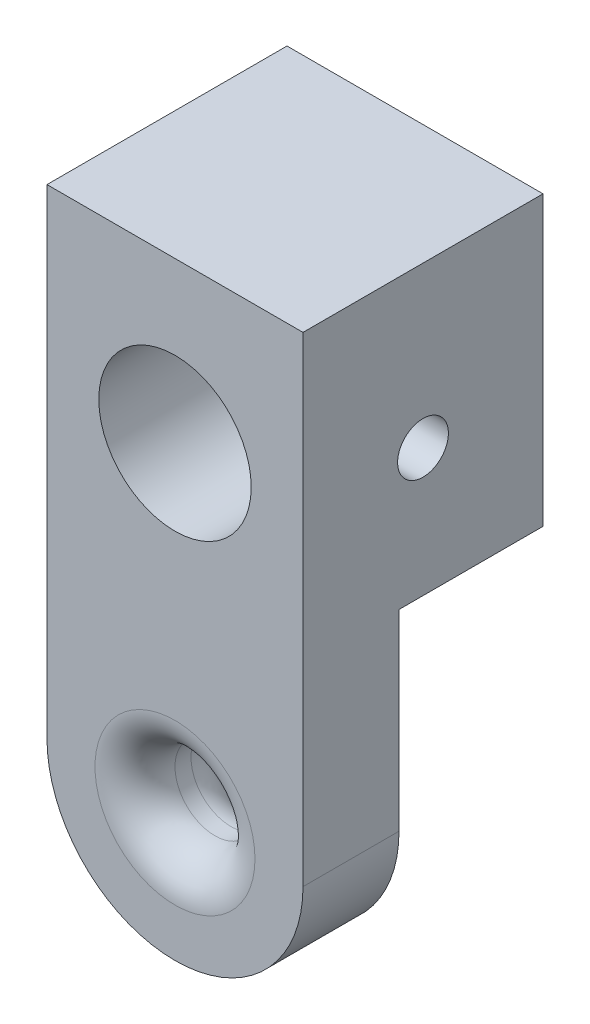
from build123d import *

# Parameters (mm, degrees)
SKETCH1_R                  = 2.5
BOSS_EXTRUDE1_DEPTH        = 15
SKETCH6_W                  = 16
SKETCH6_H                  = 20
CUT_EXTRUDE1_DEPTH         = 9
FILLET1_R                  = 2.5
F_3_8_0_3750_DOWEL_HOLE1_D = 9.525
F_1_8_0_1250_DOWEL_HOLE1_D = 3.175


with BuildPart() as part:
    # Sketch1 → Boss-Extrude1 (new body)
    with BuildSketch(Plane.XY):
        with BuildLine():
            Line((-8, 12), (-8, 0))
            ThreePointArc((-8, 0), (0, -8), (8, 0))
            Line((8, 0), (8, 12))
            Line((8, 12), (8, 30))
            Line((8, 30), (-8, 30))
            Line((-8, 30), (-8, 12))
        make_face()
        Circle(SKETCH1_R, mode=Mode.SUBTRACT)
    extrude(amount=BOSS_EXTRUDE1_DEPTH)

    # Sketch6 → Cut-Extrude1 (cut)
    with BuildSketch(Plane.XY):
        with Locations((0, 2)):
            Rectangle(SKETCH6_W, SKETCH6_H)
    extrude(amount=CUT_EXTRUDE1_DEPTH, mode=Mode.SUBTRACT)

    # Fillet1
    fillet1_edges = [part.edges().sort_by_distance(p)[0] for p in [
        (-2.5, 0, 15),
        (-2.5, 0, 9),
    ]]
    fillet(fillet1_edges, radius=FILLET1_R)

    # 3/8 (0.3750) Dowel Hole1 (through all)
    with Locations(Plane.XY.offset(15)):
        with Locations((0, 20)):
            Hole(F_3_8_0_3750_DOWEL_HOLE1_D / 2)

    # 1/8 (0.1250) Dowel Hole1 (through all)
    with Locations(Plane.ZY.offset(8)):
        with Locations((7.5, 20)):
            Hole(F_1_8_0_1250_DOWEL_HOLE1_D / 2)


solid = part.part
